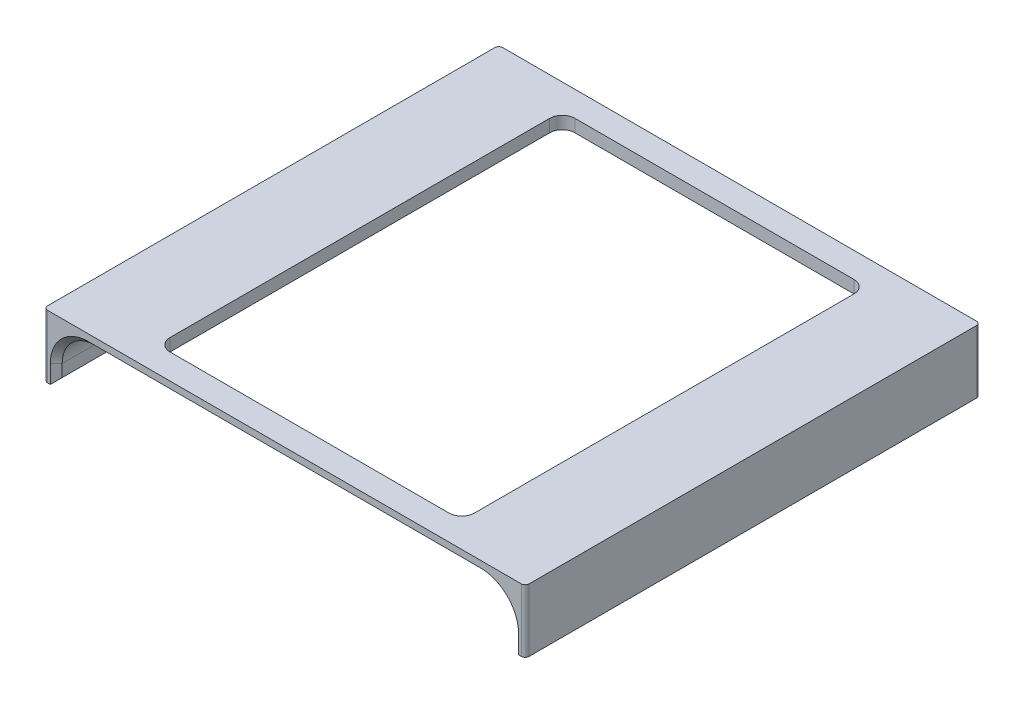
from build123d import *

# Parameters (mm, degrees)
SKETCH1_W           = 121.6152
SKETCH1_H           = 114.935
BOSS_EXTRUDE1_DEPTH = 3.175
SKETCH1_3_W         = 3.175
SKETCH1_3_H         = 114.935
BOSS_EXTRUDE2_DEPTH = 12.7
FILLET1_R           = 8.10006
CHAMFER1_SIZE       = 1.5
FILLET2_R           = 1


with BuildPart() as part:
    # Sketch1 → Boss-Extrude1 (new body)
    with BuildSketch(Plane(origin=(0, 0, 0), x_dir=(1, 0, 0), z_dir=(0, 1, 0))):
        Rectangle(SKETCH1_W, SKETCH1_H)
        with BuildLine():
            ThreePointArc((-38.4175, 47.9425), (-37.48756403, 50.18756403), (-35.2425, 51.1175))
            Line((-35.2425, 51.1175), (35.2425, 51.1175))
            ThreePointArc((35.2425, 51.1175), (37.48756403, 50.18756403), (38.4175, 47.9425))
            Line((38.4175, 47.9425), (38.4175, -47.9425))
            ThreePointArc((38.4175, -47.9425), (37.48756403, -50.18756403), (35.2425, -51.1175))
            Line((35.2425, -51.1175), (-35.2425, -51.1175))
            ThreePointArc((-35.2425, -51.1175), (-37.48756403, -50.18756403), (-38.4175, -47.9425))
            Line((-38.4175, -47.9425), (-38.4175, 47.9425))
        make_face(mode=Mode.SUBTRACT)
    extrude(amount=BOSS_EXTRUDE1_DEPTH)

    # Sketch1_3 → Boss-Extrude2 (add)
    with BuildSketch(Plane(origin=(0, 0, 0), x_dir=(1, 0, 0), z_dir=(0, 1, 0))):
        with Locations((-59.2201, 0)):
            Rectangle(SKETCH1_3_W, SKETCH1_3_H)
        with Locations((59.2201, 0)):
            Rectangle(SKETCH1_3_W, SKETCH1_3_H)
    extrude(amount=-BOSS_EXTRUDE2_DEPTH)

    # Fillet1
    fillet1_edges = [part.edges().sort_by_distance(p)[0] for p in [
        (57.6326, 0, 0),
        (-57.6326, 0, 0),
    ]]
    fillet(fillet1_edges, radius=FILLET1_R)

    # Chamfer1
    chamfer1_edges = [part.edges().sort_by_distance(p)[0] for p in [
        (-57.6326, -10.40003, 57.4675),
        (-55.260147354, -2.372452646, 57.4675),
        (0, 0, 57.4675),
        (55.260147354, -2.372452646, 57.4675),
        (57.6326, -12.7, 0),
        (57.6326, -10.40003, 57.4675),
        (57.6326, -10.40003, -57.4675),
        (55.260147354, -2.372452646, -57.4675),
        (0, 0, -57.4675),
        (-55.260147354, -2.372452646, -57.4675),
        (-57.6326, -12.7, 0),
        (-57.6326, -10.40003, -57.4675),
    ]]
    chamfer(chamfer1_edges, length=CHAMFER1_SIZE)

    # Fillet2
    fillet2_edges = [part.edges().sort_by_distance(p)[0] for p in [
        (-60.8076, -4.7625, 57.4675),
        (-60.8076, -4.7625, -57.4675),
        (60.8076, -4.7625, -57.4675),
        (60.8076, -4.7625, 57.4675),
    ]]
    fillet(fillet2_edges, radius=FILLET2_R)


solid = part.part
